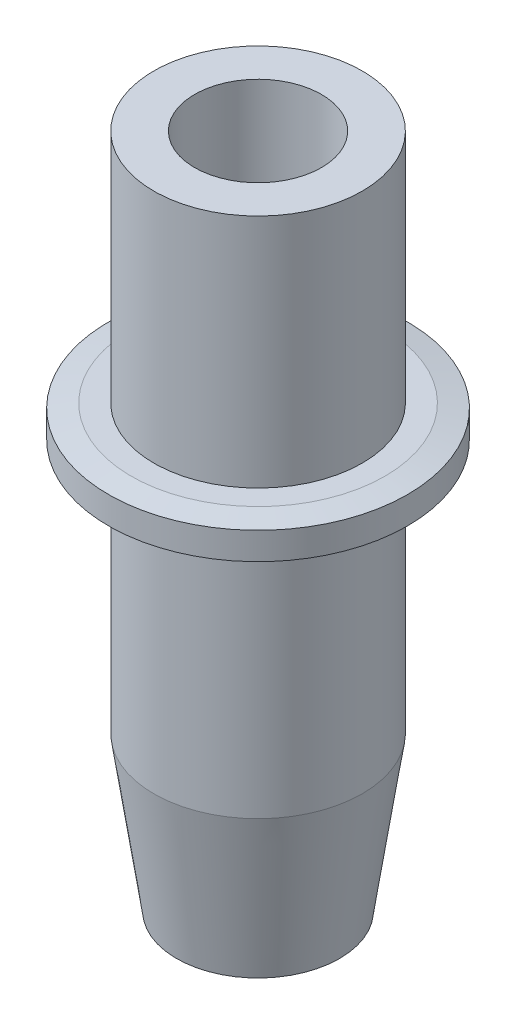
from build123d import *

# Parameters (mm, degrees)
CHAMFER1_SIZE  = 1
CHAMFER1_SIZE2 = 2.246036774


with BuildPart() as part:
    # Sketch1 → Revolve1 (revolve)
    with BuildSketch(Plane.XY):
        Polygon((0, 0), (4.5, 0), (5.75, 8.5), (5.75, 22.3), (7, 22.3), (8.25, 22.55), (8.25, 24.05), (7, 24.3), (5.75, 24.3), (5.75, 37.3), (0, 37.3), align=None)
    revolve(axis=Axis((0, -143.950460456, 0), (0, 1, 0)))

    # Sketch2 → Cut-Revolve1 (revolve, cut)
    with BuildSketch(Plane.XY):
        Polygon((1.1, 0), (1.1, 2), (2.5, 2), (2.5, 14.18), (3.5, 14.18), (3.5, 37.3), (0, 37.3), (0, 0), align=None)
    revolve(axis=Axis((0, -1000, 0), (0, 1, 0)), mode=Mode.SUBTRACT)

    # Chamfer1
    chamfer1_edges = [part.edges().sort_by_distance(p)[0] for p in [
        (-2.5, 2, 0),
    ]]
    chamfer1_side = [part.faces().sort_by_distance(p)[0] for p in [
        (-1.170710678, 2, 0),
    ]]
    chamfer(chamfer1_edges, length=CHAMFER1_SIZE, length2=CHAMFER1_SIZE2, reference=chamfer1_side[0])


solid = part.part
